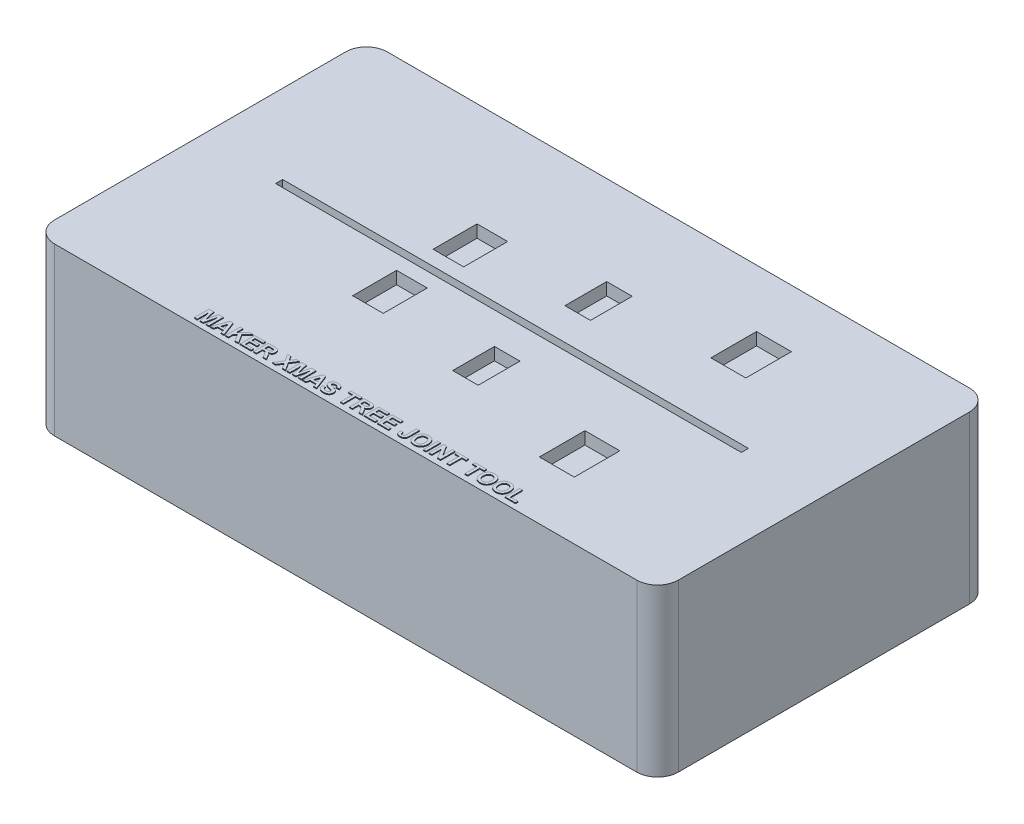
from build123d import *

# Parameters (mm, degrees)
SALIENTE_EXTRUIR1_DEPTH = 40
CROQUIS2_W              = 112
CROQUIS2_H              = 1.7
CORTAR_EXTRUIR1_DEPTH   = 37
CROQUIS4_W              = 0.673076923
CROQUIS4_H              = 3.5
SALIENTE_EXTRUIR2_DEPTH = 0.2
CROQUIS5_W              = 8.389594621
CROQUIS5_H              = 10.964379778
CROQUIS5_W_2            = 6.134235593
CROQUIS5_H_2            = 10.040470523
CROQUIS5_W_3            = 7.354274735
CROQUIS5_H_3            = 10.576819317
CROQUIS5_W_4            = 7.36371539
CROQUIS5_H_4            = 10.570248785
CROQUIS5_W_5            = 6.125268444
CROQUIS5_H_5            = 10.045943517
CROQUIS5_W_6            = 8.3993809
CROQUIS5_H_6            = 10.9568847
CORTAR_EXTRUIR2_DEPTH   = 3


with BuildPart() as part:
    # Croquis1 → Saliente-Extruir1 (new body)
    with BuildSketch(Plane(origin=(0, 0, 0), x_dir=(1, 0, 0), z_dir=(0, 1, 0))):
        with BuildLine():
            Line((-70, 40), (70, 40))
            ThreePointArc((70, 40), (73.535533906, 38.535533906), (75, 35))
            Line((75, 35), (75, -35))
            ThreePointArc((75, -35), (73.535533906, -38.535533906), (70, -40))
            Line((70, -40), (-70, -40))
            ThreePointArc((-70, -40), (-73.535533906, -38.535533906), (-75, -35))
            Line((-75, -35), (-75, 35))
            ThreePointArc((-75, 35), (-73.535533906, 38.535533906), (-70, 40))
        make_face()
    extrude(amount=SALIENTE_EXTRUIR1_DEPTH)

    # Croquis2 → Cortar-Extruir1 (cut)
    with BuildSketch(Plane(origin=(0, 40, 0), x_dir=(1, 0, 0), z_dir=(0, 1, 0))):
        Rectangle(CROQUIS2_W, CROQUIS2_H)
    extrude(amount=-CORTAR_EXTRUIR1_DEPTH, mode=Mode.SUBTRACT)

    # Croquis4 → Saliente-Extruir2 (add)
    with BuildSketch(Plane(origin=(0, 40, 0), x_dir=(1, 0, 0), z_dir=(0, 1, 0))):
        Polygon((-37.657952592, -38.693059619), (-37.657952592, -35.193059619), (-36.519330797, -35.193059619), (-35.93038849, -37.580379331), (-35.341446182, -35.193059619), (-34.202824387, -35.193059619), (-34.202824387, -38.693059619), (-34.87590131, -38.693059619), (-34.898337208, -35.937650965), (-35.555288329, -38.693059619), (-36.30548865, -38.693059619), (-36.962439772, -35.937650965), (-36.984875669, -38.693059619), align=None)
        Polygon((-30.523337208, -38.693059619), (-31.237079195, -38.693059619), (-31.532251471, -37.885367311), (-32.875600829, -37.885367311), (-33.170773105, -38.693059619), (-33.888721823, -38.693059619), (-32.565704996, -35.193059619), (-31.852664131, -35.193059619), align=None)
        Polygon((-31.746093618, -37.302033978), (-32.206029515, -36.045623722), (-32.664563169, -37.302033978), align=None, mode=Mode.SUBTRACT)
        Polygon((-30.164362849, -38.693059619), (-30.164362849, -35.193059619), (-29.491285926, -35.193059619), (-29.491285926, -36.760066831), (-28.015424547, -35.193059619), (-27.0906449, -35.193059619), (-28.419971823, -36.546224683), (-27.045773105, -38.693059619), (-27.942507881, -38.693059619), (-28.93038849, -37.067158177), (-29.491285926, -37.637871318), (-29.491285926, -38.693059619), align=None)
        Polygon((-26.664362849, -38.693059619), (-26.664362849, -35.193059619), (-24.061798746, -35.193059619), (-24.061798746, -35.776392952), (-25.991285926, -35.776392952), (-25.991285926, -36.539213465), (-24.196414131, -36.539213465), (-24.196414131, -37.122546799), (-25.991285926, -37.122546799), (-25.991285926, -38.109726286), (-24.016926951, -38.109726286), (-24.016926951, -38.693059619), align=None)
        with BuildLine():
            Line((-23.433593618, -38.693059619), (-23.433593618, -35.193059619))
            Line((-23.433593618, -35.193059619), (-21.964743458, -35.193059619))
            add(Edge.make_bspline(
                [(-21.964743458, -35.193059619), (-21.920103649, -35.193334733), (-21.834074569, -35.193864929), (-21.709659735, -35.197731218), (-21.594921331, -35.205831321), (-21.489350375, -35.215004753), (-21.393453933, -35.228351506), (-21.306852848, -35.244340785), (-21.229692919, -35.262870154), (-21.160848337, -35.285062079), (-21.098076063, -35.310461508), (-21.03960061, -35.340693974), (-20.984779023, -35.376115024), (-20.932769297, -35.415503792), (-20.88335119, -35.4589208), (-20.837879486, -35.507515075), (-20.795561946, -35.560563036), (-20.756432715, -35.617623317), (-20.721962312, -35.678443965), (-20.690465414, -35.741071711), (-20.664825751, -35.806173007), (-20.643647622, -35.873441179), (-20.626730206, -35.942730177), (-20.61498809, -36.01421616), (-20.607657614, -36.087769737), (-20.607003221, -36.137453045), (-20.606670541, -36.162711061)],
                knots=[0, 0, 0, 0, 0.000133922, 0.000258091, 0.000373334, 0.000478959, 0.000575932, 0.000663665, 0.000743078, 0.000813807, 0.000880469, 0.000946008, 0.001010967, 0.001076032, 0.001141593, 0.001208056, 0.001275396, 0.001345016, 0.00141537, 0.001484979, 0.001555154, 0.001625003, 0.001696424, 0.001768925, 0.001842178, 0.001917929, 0.001917929, 0.001917929, 0.001917929], degree=3))
            add(Edge.make_bspline(
                [(-20.606670541, -36.162711061), (-20.607287613, -36.194529093), (-20.608493542, -36.256710296), (-20.619591138, -36.347848588), (-20.636073902, -36.434924721), (-20.659569955, -36.51805933), (-20.69187655, -36.596274634), (-20.729380558, -36.670666319), (-20.774110387, -36.740982044), (-20.825762148, -36.806524739), (-20.884289599, -36.867352422), (-20.949949229, -36.922213305), (-21.02227225, -36.971321798), (-21.101696172, -37.014394712), (-21.187667961, -37.051217385), (-21.280560419, -37.082198861), (-21.379953023, -37.107414331), (-21.449090463, -37.119278963), (-21.484475028, -37.125351286)],
                knots=[0, 0, 0, 0, 9.5417e-05, 0.000186471, 0.000275024, 0.000361122, 0.000445099, 0.000528506, 0.000610779, 0.000694656, 0.000778454, 0.000863556, 0.00095087, 0.001040287, 0.001134191, 0.00123108, 0.001333789, 0.001441463, 0.001441463, 0.001441463, 0.001441463], degree=3))
            add(Edge.make_bspline(
                [(-21.484475028, -37.125351286), (-21.45025418, -37.148016075), (-21.383279318, -37.192374156), (-21.290614776, -37.265432471), (-21.207424003, -37.342112824), (-21.144436147, -37.410301763), (-21.09603647, -37.47026661), (-21.057066461, -37.522712443), (-21.01503106, -37.58306999), (-20.97034254, -37.651371953), (-20.921679798, -37.727014023), (-20.870852687, -37.811154016), (-20.816797578, -37.902971221), (-20.780454085, -37.967110186), (-20.761618458, -38.000351286)],
                knots=[0, 0, 0, 0, 0.000123098, 0.00024092, 0.000353548, 0.000462213, 0.000519043, 0.000584668, 0.000658189, 0.000739667, 0.000829522, 0.000928002, 0.00103454, 0.001149158, 0.001149158, 0.001149158, 0.001149158], degree=3))
            Line((-20.761618458, -38.000351286), (-20.337439772, -38.693059619))
            Line((-20.337439772, -38.693059619), (-21.124098426, -38.693059619))
            Line((-21.124098426, -38.693059619), (-21.6218949, -37.898688626))
            add(Edge.make_bspline(
                [(-21.6218949, -37.898688626), (-21.644756682, -37.866874641), (-21.688404523, -37.806135203), (-21.751412879, -37.71982249), (-21.809059933, -37.642988674), (-21.859811503, -37.57452086), (-21.906235599, -37.516360271), (-21.9469226, -37.467493372), (-21.981043765, -37.426871549), (-22.019651947, -37.386593257), (-22.064568468, -37.345198393), (-22.120171534, -37.305063716), (-22.177270723, -37.273068775), (-22.238447944, -37.248655883), (-22.309197551, -37.231633593), (-22.394249783, -37.22078823), (-22.496278881, -37.212786643), (-22.570025478, -37.212464192), (-22.609775509, -37.212290388)],
                knots=[0, 0, 0, 0, 0.000117529, 0.000224388, 0.000320582, 0.000405698, 0.000480047, 0.000543784, 0.000596485, 0.000639132, 0.000711102, 0.000779403, 0.00084437, 0.000906993, 0.000976373, 0.001062042, 0.001163996, 0.001283206, 0.001283206, 0.001283206, 0.001283206], degree=3))
            Line((-22.609775509, -37.212290388), (-22.760516695, -37.212290388))
            Line((-22.760516695, -37.212290388), (-22.760516695, -38.693059619))
            Line((-22.760516695, -38.693059619), (-23.433593618, -38.693059619))
        make_face()
        with BuildLine():
            Line((-22.760516695, -36.628957055), (-22.218549547, -36.628957055))
            add(Edge.make_bspline(
                [(-22.218549547, -36.628957055), (-22.176713927, -36.628867399), (-22.097010001, -36.628696588), (-21.983669433, -36.626222469), (-21.882418141, -36.624122541), (-21.793862038, -36.618846382), (-21.717604917, -36.613617212), (-21.653952684, -36.606821187), (-21.602369051, -36.598788505), (-21.550845672, -36.586299794), (-21.498068226, -36.564540681), (-21.441817453, -36.533549299), (-21.39374131, -36.493345071), (-21.352096266, -36.446864918), (-21.320326932, -36.392223271), (-21.295444029, -36.331854477), (-21.28282787, -36.264417088), (-21.280795781, -36.217674195), (-21.279747464, -36.19356042)],
                knots=[0, 0, 0, 0, 0.000125503, 0.000239104, 0.000340104, 0.000429282, 0.000505211, 0.000569397, 0.000621266, 0.000661737, 0.000728136, 0.000791881, 0.000853643, 0.000915246, 0.000978133, 0.001042319, 0.001110244, 0.001182626, 0.001182626, 0.001182626, 0.001182626], degree=3))
            add(Edge.make_bspline(
                [(-21.279747464, -36.19356042), (-21.280939727, -36.166584178), (-21.283240007, -36.114537867), (-21.301380338, -36.040475471), (-21.333043546, -35.975051541), (-21.376529149, -35.91815806), (-21.431118474, -35.870116384), (-21.496140395, -35.831981751), (-21.571111848, -35.803580658), (-21.625186101, -35.793092189), (-21.653445381, -35.787610901)],
                knots=[0, 0, 0, 0, 8.0876e-05, 0.000156036, 0.000226905, 0.00029744, 0.000369465, 0.000443655, 0.000522434, 0.000608671, 0.000608671, 0.000608671, 0.000608671], degree=3))
            add(Edge.make_bspline(
                [(-21.653445381, -35.787610901), (-21.662786514, -35.786584511), (-21.684926962, -35.784151752), (-21.724024369, -35.782589297), (-21.774015419, -35.780187635), (-21.835505204, -35.779206128), (-21.907944378, -35.777485635), (-21.991620992, -35.777169709), (-22.086269198, -35.776160347), (-22.153111108, -35.776312579), (-22.18840131, -35.776392952)],
                knots=[0, 0, 0, 0, 2.8185e-05, 6.6804e-05, 0.000117328, 0.000178342, 0.000251272, 0.000334709, 0.000429363, 0.000535232, 0.000535232, 0.000535232, 0.000535232], degree=3))
            Line((-22.18840131, -35.776392952), (-22.760516695, -35.776392952))
            Line((-22.760516695, -35.776392952), (-22.760516695, -36.628957055))
        make_face(mode=Mode.SUBTRACT)
        Polygon((-18.923978233, -38.693059619), (-17.724358842, -36.839293593), (-18.789362849, -35.193059619), (-18.002704195, -35.193059619), (-17.331029515, -36.231420997), (-16.659354836, -35.193059619), (-15.872696182, -35.193059619), (-16.937700188, -36.839293593), (-15.738080797, -38.693059619), (-16.524739451, -38.693059619), (-17.331029515, -37.44716619), (-18.137319579, -38.693059619), align=None)
        Polygon((-15.401542336, -38.693059619), (-15.401542336, -35.193059619), (-14.262920541, -35.193059619), (-13.673978233, -37.580379331), (-13.085035926, -35.193059619), (-11.946414131, -35.193059619), (-11.946414131, -38.693059619), (-12.619491054, -38.693059619), (-12.641926951, -35.937650965), (-13.298878073, -38.693059619), (-14.049078394, -38.693059619), (-14.706029515, -35.937650965), (-14.728465413, -38.693059619), align=None)
        Polygon((-8.266926951, -38.693059619), (-8.980668938, -38.693059619), (-9.275841214, -37.885367311), (-10.619190573, -37.885367311), (-10.914362849, -38.693059619), (-11.632311567, -38.693059619), (-10.30929474, -35.193059619), (-9.596253874, -35.193059619), align=None)
        Polygon((-9.489683362, -37.302033978), (-9.949619259, -36.045623722), (-10.408152913, -37.302033978), align=None, mode=Mode.SUBTRACT)
        with BuildLine():
            Line((-8.087439772, -37.526392952), (-7.414362849, -37.481521158))
            add(Edge.make_bspline(
                [(-7.414362849, -37.481521158), (-7.409000635, -37.509680326), (-7.398584877, -37.564377719), (-7.375443018, -37.642328972), (-7.349970236, -37.715001648), (-7.319528865, -37.781616453), (-7.28620334, -37.843404726), (-7.247255956, -37.898606268), (-7.205403781, -37.948983523), (-7.158575052, -37.992727155), (-7.107555759, -38.031038432), (-7.052091322, -38.063711565), (-6.992782745, -38.091990752), (-6.929485012, -38.115277766), (-6.861545742, -38.132661636), (-6.789556787, -38.145029228), (-6.713414901, -38.152949093), (-6.661377985, -38.154039421), (-6.634715413, -38.154598081)],
                knots=[0, 0, 0, 0, 8.5941e-05, 0.000166935, 0.000243669, 0.000316781, 0.000386446, 0.000453936, 0.00051911, 0.0005826, 0.000645701, 0.00071015, 0.000775381, 0.00084259, 0.000912143, 0.000985453, 0.001061566, 0.001141543, 0.001141543, 0.001141543, 0.001141543], degree=3))
            add(Edge.make_bspline(
                [(-6.634715413, -38.154598081), (-6.606651369, -38.154291904), (-6.552065358, -38.153696374), (-6.472964193, -38.146308302), (-6.39900101, -38.135724093), (-6.330828931, -38.118969539), (-6.267174908, -38.100232222), (-6.20961984, -38.074597576), (-6.157232351, -38.045031717), (-6.110147403, -38.011482128), (-6.069056325, -37.974273226), (-6.033107799, -37.93542834), (-6.001799007, -37.895786697), (-5.977156772, -37.853589174), (-5.957214142, -37.810542414), (-5.94403346, -37.765362258), (-5.935129129, -37.719086139), (-5.934108062, -37.687459566), (-5.933593618, -37.671525164)],
                knots=[0, 0, 0, 0, 8.4161e-05, 0.000163697, 0.000238165, 0.000308059, 0.000374144, 0.000436932, 0.000496589, 0.000554376, 0.000609981, 0.00066257, 0.000713056, 0.000761153, 0.00080885, 0.000854985, 0.000902018, 0.000949777, 0.000949777, 0.000949777, 0.000949777], degree=3))
            add(Edge.make_bspline(
                [(-5.933593618, -37.671525164), (-5.93422454, -37.651560651), (-5.935458846, -37.612503003), (-5.950318653, -37.556665816), (-5.972603327, -37.504934276), (-6.006156345, -37.458072458), (-6.051259861, -37.415247586), (-6.108793889, -37.375185966), (-6.180364404, -37.339146177), (-6.233460416, -37.319043115), (-6.261718618, -37.308344074)],
                knots=[0, 0, 0, 0, 5.9744e-05, 0.00011688, 0.000172122, 0.000227952, 0.000288444, 0.000357887, 0.000437535, 0.00052815, 0.00052815, 0.00052815, 0.00052815], degree=3))
            add(Edge.make_bspline(
                [(-6.261718618, -37.308344074), (-6.273843464, -37.304280982), (-6.300976901, -37.295188442), (-6.347263664, -37.282186968), (-6.4030173, -37.26595158), (-6.469043483, -37.24749747), (-6.545320013, -37.228623774), (-6.630994981, -37.205373522), (-6.727112859, -37.18223762), (-6.794357043, -37.165158703), (-6.829627272, -37.156200645)],
                knots=[0, 0, 0, 0, 3.8357e-05, 8.5837e-05, 0.000144199, 0.000212579, 0.000291482, 0.000379913, 0.00047888, 0.000588051, 0.000588051, 0.000588051, 0.000588051], degree=3))
            add(Edge.make_bspline(
                [(-6.829627272, -37.156200645), (-6.875559578, -37.14473242), (-6.964178452, -37.122606355), (-7.090569258, -37.083245654), (-7.206977503, -37.044138618), (-7.312282362, -37.001705386), (-7.407645393, -36.958821771), (-7.491524069, -36.912477061), (-7.565668754, -36.865078099), (-7.608874583, -36.829650957), (-7.62960724, -36.812650965)],
                knots=[0, 0, 0, 0, 0.000141996, 0.000273958, 0.000397014, 0.000510284, 0.00061444, 0.00071046, 0.00079758, 0.000877953, 0.000877953, 0.000877953, 0.000877953], degree=3))
            add(Edge.make_bspline(
                [(-7.62960724, -36.812650965), (-7.655318429, -36.78857769), (-7.705727592, -36.741379807), (-7.772083432, -36.663824627), (-7.827840406, -36.581899988), (-7.8737345, -36.496210603), (-7.909072084, -36.406263162), (-7.934118909, -36.312659736), (-7.950330125, -36.215156029), (-7.951984367, -36.148753695), (-7.952824387, -36.115034779)],
                knots=[0, 0, 0, 0, 0.000105609, 0.000207056, 0.000305456, 0.000402376, 0.000498071, 0.000594675, 0.000692652, 0.000793733, 0.000793733, 0.000793733, 0.000793733], degree=3))
            add(Edge.make_bspline(
                [(-7.952824387, -36.115034779), (-7.951188442, -36.071402905), (-7.947943215, -35.984850289), (-7.918182368, -35.857629759), (-7.871823101, -35.734871747), (-7.818057343, -35.637397339), (-7.766400051, -35.56365758), (-7.72350243, -35.510742604), (-7.676375249, -35.461219274), (-7.624372966, -35.41629562), (-7.569426553, -35.373340206), (-7.509407176, -35.335195284), (-7.446016566, -35.299264878), (-7.354283131, -35.256671053), (-7.229734298, -35.212284104), (-7.067689575, -35.174868723), (-6.891254959, -35.152377246), (-6.768932297, -35.149618017), (-6.705528714, -35.148187824)],
                knots=[0, 0, 0, 0, 0.000130727, 0.000259323, 0.000389799, 0.000523479, 0.000591945, 0.000659726, 0.000727662, 0.000796718, 0.000865714, 0.000936697, 0.001009836, 0.001084171, 0.001239855, 0.001405498, 0.001582208, 0.001772369, 0.001772369, 0.001772369, 0.001772369], degree=3))
            add(Edge.make_bspline(
                [(-6.705528714, -35.148187824), (-6.653613807, -35.148882057), (-6.552640422, -35.150232324), (-6.406267772, -35.163886442), (-6.269547775, -35.185137462), (-6.142960198, -35.215643203), (-6.02644606, -35.255949293), (-5.919553717, -35.303961467), (-5.822374003, -35.360963965), (-5.736089984, -35.427283905), (-5.659219194, -35.500397385), (-5.592161723, -35.580258524), (-5.534661198, -35.665858727), (-5.486346517, -35.757135436), (-5.448405125, -35.854557947), (-5.420538671, -35.958004696), (-5.402107556, -36.067232196), (-5.397487741, -36.14207597), (-5.395132079, -36.180239106)],
                knots=[0, 0, 0, 0, 0.000155706, 0.000302845, 0.000440588, 0.000570506, 0.000692899, 0.000809936, 0.000921522, 0.00103006, 0.001135688, 0.001239193, 0.001342256, 0.001444497, 0.001548396, 0.001655208, 0.0017654, 0.001880046, 0.001880046, 0.001880046, 0.001880046], degree=3))
            Line((-5.395132079, -36.180239106), (-6.068209003, -36.225110901))
            add(Edge.make_bspline(
                [(-6.068209003, -36.225110901), (-6.072091813, -36.204005014), (-6.079659008, -36.162871835), (-6.096112161, -36.103960766), (-6.114670519, -36.049474746), (-6.136392116, -35.999414126), (-6.16262918, -35.954675537), (-6.191182646, -35.913851482), (-6.222840173, -35.877485916), (-6.258649955, -35.846574648), (-6.297381415, -35.81844666), (-6.341521628, -35.795901427), (-6.389221072, -35.774984413), (-6.442294421, -35.759259948), (-6.499722474, -35.746786737), (-6.561538683, -35.73753991), (-6.627871184, -35.733025088), (-6.673505499, -35.732033944), (-6.697115253, -35.731521158)],
                knots=[0, 0, 0, 0, 6.4351e-05, 0.000125413, 0.000183284, 0.00023696, 0.000288791, 0.00033859, 0.000386277, 0.000432974, 0.000480246, 0.00052949, 0.00058132, 0.000636322, 0.000695183, 0.000757551, 0.000823639, 0.000894483, 0.000894483, 0.000894483, 0.000894483], degree=3))
            add(Edge.make_bspline(
                [(-6.697115253, -35.731521158), (-6.721662948, -35.731973864), (-6.769421587, -35.732854624), (-6.839018652, -35.738259719), (-6.904305922, -35.748237003), (-6.965604039, -35.761224953), (-7.022831124, -35.77889416), (-7.075866411, -35.800438864), (-7.12495254, -35.825803613), (-7.154883121, -35.845759721), (-7.169671342, -35.855619715)],
                knots=[0, 0, 0, 0, 7.3648e-05, 0.000143285, 0.000209224, 0.000271659, 0.000331094, 0.000388641, 0.000443207, 0.000496497, 0.000496497, 0.000496497, 0.000496497], degree=3))
            add(Edge.make_bspline(
                [(-7.169671342, -35.855619715), (-7.18659522, -35.869088748), (-7.219371518, -35.895174082), (-7.254645751, -35.946970688), (-7.275880921, -36.005473401), (-7.278436814, -36.046844644), (-7.279747464, -36.068059619)],
                knots=[0, 0, 0, 0, 6.4572e-05, 0.000125055, 0.000185376, 0.000248866, 0.000248866, 0.000248866, 0.000248866], degree=3))
            add(Edge.make_bspline(
                [(-7.279747464, -36.068059619), (-7.278675591, -36.087886422), (-7.276564173, -36.126942068), (-7.255267797, -36.182421458), (-7.222516872, -36.233827103), (-7.191916504, -36.261751324), (-7.175981438, -36.276292792)],
                knots=[0, 0, 0, 0, 5.9231e-05, 0.000116676, 0.00017599, 0.00024044, 0.00024044, 0.00024044, 0.00024044], degree=3))
            add(Edge.make_bspline(
                [(-7.175981438, -36.276292792), (-7.163334911, -36.285730935), (-7.135075185, -36.306821255), (-7.083308969, -36.333629048), (-7.020825788, -36.362663506), (-6.946201176, -36.391047895), (-6.859931086, -36.419379595), (-6.762010273, -36.448961165), (-6.652378511, -36.478939896), (-6.53383026, -36.507972828), (-6.413470395, -36.536510532), (-6.298614294, -36.567710298), (-6.191814636, -36.598127656), (-6.093566622, -36.630009984), (-6.003363801, -36.661047331), (-5.921644346, -36.692924922), (-5.847847141, -36.723970129), (-5.761791419, -36.766659487), (-5.664255913, -36.824483948), (-5.562027699, -36.908541445), (-5.47161989, -37.003027562), (-5.408626131, -37.092121453), (-5.365352715, -37.16874457), (-5.3374892, -37.229822116), (-5.313385075, -37.294182449), (-5.293764383, -37.361896691), (-5.279544102, -37.433060126), (-5.267775992, -37.507129063), (-5.261763446, -37.584718661), (-5.260936751, -37.637629246), (-5.260516695, -37.664513946)],
                knots=[0, 0, 0, 0, 4.7272e-05, 0.000105634, 0.000174337, 0.000254022, 0.000344924, 0.000446732, 0.000560862, 0.000685847, 0.000812874, 0.000931924, 0.00104287, 0.001145973, 0.001241763, 0.001328998, 0.001409092, 0.001481836, 0.001617109, 0.001748182, 0.001877624, 0.002008356, 0.002074276, 0.002141412, 0.002209522, 0.002280308, 0.002352635, 0.002427103, 0.002505183, 0.002585839, 0.002585839, 0.002585839, 0.002585839], degree=3))
            add(Edge.make_bspline(
                [(-5.260516695, -37.664513946), (-5.261094286, -37.68930765), (-5.262241326, -37.738545546), (-5.270257155, -37.811627012), (-5.282653432, -37.883410687), (-5.301004182, -37.95398656), (-5.325348325, -38.023215792), (-5.352757895, -38.092097555), (-5.387032018, -38.15912968), (-5.426040646, -38.224367687), (-5.469068934, -38.28776262), (-5.517827977, -38.346243002), (-5.569453859, -38.401759878), (-5.627245336, -38.451204615), (-5.687633655, -38.498580779), (-5.753380915, -38.540537906), (-5.822946754, -38.578505392), (-5.896771024, -38.61219977), (-5.975115474, -38.641561374), (-6.057878349, -38.667695244), (-6.145805294, -38.689083809), (-6.238163123, -38.707416504), (-6.335289826, -38.721358044), (-6.437063971, -38.731092481), (-6.543508697, -38.736582117), (-6.616012715, -38.73747606), (-6.652944579, -38.737931414)],
                knots=[0, 0, 0, 0, 7.4372e-05, 0.000147695, 0.000220315, 0.000292758, 0.000366148, 0.000440361, 0.000514987, 0.000591701, 0.000668326, 0.000744542, 0.000819925, 0.000895445, 0.000972434, 0.001050031, 0.001129096, 0.001210042, 0.001293251, 0.001379955, 0.00147025, 0.001564577, 0.001662342, 0.001764478, 0.001871196, 0.001981993, 0.001981993, 0.001981993, 0.001981993], degree=3))
            add(Edge.make_bspline(
                [(-6.652944579, -38.737931414), (-6.706268494, -38.73706081), (-6.81009142, -38.735365725), (-6.960927486, -38.720193373), (-7.10240173, -38.696970994), (-7.234283843, -38.663267489), (-7.356735017, -38.619999796), (-7.469699403, -38.566703553), (-7.572630607, -38.503060341), (-7.666803485, -38.430613617), (-7.750963333, -38.348043219), (-7.826640037, -38.257059973), (-7.892812698, -38.156844591), (-7.949437821, -38.047553824), (-7.997946987, -37.929778495), (-8.037952963, -37.803464524), (-8.068075361, -37.668009462), (-8.080873332, -37.574414874), (-8.087439772, -37.526392952)],
                knots=[0, 0, 0, 0, 0.000159931, 0.00031139, 0.000454317, 0.000589677, 0.000719186, 0.000843377, 0.000963627, 0.00108157, 0.001199076, 0.001316585, 0.001435982, 0.0015586, 0.001685288, 0.001817666, 0.001955616, 0.00210098, 0.00210098, 0.00210098, 0.00210098], degree=3))
        make_face()
        Polygon((-2.523337208, -38.693059619), (-2.523337208, -35.776392952), (-3.55538849, -35.776392952), (-3.55538849, -35.193059619), (-0.818209003, -35.193059619), (-0.818209003, -35.776392952), (-1.850260285, -35.776392952), (-1.850260285, -38.693059619), align=None)
        with BuildLine():
            Line((-0.369491054, -38.693059619), (-0.369491054, -35.193059619))
            Line((-0.369491054, -35.193059619), (1.099359106, -35.193059619))
            add(Edge.make_bspline(
                [(1.099359106, -35.193059619), (1.143998915, -35.193334733), (1.230027995, -35.193864929), (1.354442829, -35.197731218), (1.469181233, -35.205831321), (1.574752189, -35.215004753), (1.670648631, -35.228351506), (1.757249716, -35.244340785), (1.834409645, -35.262870154), (1.903254227, -35.285062079), (1.966026501, -35.310461508), (2.024501954, -35.340693974), (2.079323541, -35.376115024), (2.131333267, -35.415503792), (2.180751374, -35.4589208), (2.226223078, -35.507515075), (2.268540618, -35.560563036), (2.307669849, -35.617623317), (2.342140252, -35.678443965), (2.37363715, -35.741071711), (2.399276813, -35.806173007), (2.420454942, -35.873441179), (2.437372358, -35.942730177), (2.449114474, -36.01421616), (2.45644495, -36.087769737), (2.457099343, -36.137453045), (2.457432023, -36.162711061)],
                knots=[0, 0, 0, 0, 0.000133922, 0.000258091, 0.000373334, 0.000478959, 0.000575932, 0.000663665, 0.000743078, 0.000813807, 0.000880469, 0.000946008, 0.001010967, 0.001076032, 0.001141593, 0.001208056, 0.001275396, 0.001345016, 0.00141537, 0.001484979, 0.001555154, 0.001625003, 0.001696424, 0.001768925, 0.001842178, 0.001917929, 0.001917929, 0.001917929, 0.001917929], degree=3))
            add(Edge.make_bspline(
                [(2.457432023, -36.162711061), (2.456814951, -36.194529093), (2.455609022, -36.256710296), (2.444511426, -36.347848588), (2.428028662, -36.434924721), (2.404532609, -36.51805933), (2.372226014, -36.596274634), (2.334722006, -36.670666319), (2.289992177, -36.740982044), (2.238340416, -36.806524739), (2.179812965, -36.867352422), (2.114153335, -36.922213305), (2.041830314, -36.971321798), (1.962406393, -37.014394712), (1.876434604, -37.051217385), (1.783542145, -37.082198861), (1.684149541, -37.107414331), (1.615012101, -37.119278963), (1.579627536, -37.125351286)],
                knots=[0, 0, 0, 0, 9.5417e-05, 0.000186471, 0.000275024, 0.000361122, 0.000445099, 0.000528506, 0.000610779, 0.000694656, 0.000778454, 0.000863556, 0.00095087, 0.001040287, 0.001134191, 0.00123108, 0.001333789, 0.001441463, 0.001441463, 0.001441463, 0.001441463], degree=3))
            add(Edge.make_bspline(
                [(1.579627536, -37.125351286), (1.613848384, -37.148016075), (1.680823246, -37.192374156), (1.773487788, -37.265432471), (1.856678561, -37.342112824), (1.919666417, -37.410301763), (1.968066094, -37.47026661), (2.007036103, -37.522712443), (2.049071505, -37.58306999), (2.093760024, -37.651371953), (2.142422766, -37.727014023), (2.193249877, -37.811154016), (2.247304986, -37.902971221), (2.283648479, -37.967110186), (2.302484106, -38.000351286)],
                knots=[0, 0, 0, 0, 0.000123098, 0.00024092, 0.000353548, 0.000462213, 0.000519043, 0.000584668, 0.000658189, 0.000739667, 0.000829522, 0.000928002, 0.00103454, 0.001149158, 0.001149158, 0.001149158, 0.001149158], degree=3))
            Line((2.302484106, -38.000351286), (2.726662792, -38.693059619))
            Line((2.726662792, -38.693059619), (1.940004138, -38.693059619))
            Line((1.940004138, -38.693059619), (1.442207664, -37.898688626))
            add(Edge.make_bspline(
                [(1.442207664, -37.898688626), (1.419345882, -37.866874641), (1.375698041, -37.806135203), (1.312689685, -37.71982249), (1.255042632, -37.642988674), (1.204291061, -37.57452086), (1.157866965, -37.516360271), (1.117179964, -37.467493372), (1.083058799, -37.426871549), (1.044450617, -37.386593257), (0.999534096, -37.345198393), (0.94393103, -37.305063716), (0.886831841, -37.273068775), (0.82565462, -37.248655883), (0.754905013, -37.231633593), (0.669852781, -37.22078823), (0.567823683, -37.212786643), (0.494077086, -37.212464192), (0.454327055, -37.212290388)],
                knots=[0, 0, 0, 0, 0.000117529, 0.000224388, 0.000320582, 0.000405698, 0.000480047, 0.000543784, 0.000596485, 0.000639132, 0.000711102, 0.000779403, 0.00084437, 0.000906993, 0.000976373, 0.001062042, 0.001163996, 0.001283206, 0.001283206, 0.001283206, 0.001283206], degree=3))
            Line((0.454327055, -37.212290388), (0.303585869, -37.212290388))
            Line((0.303585869, -37.212290388), (0.303585869, -38.693059619))
            Line((0.303585869, -38.693059619), (-0.369491054, -38.693059619))
        make_face()
        with BuildLine():
            Line((0.303585869, -36.628957055), (0.845553017, -36.628957055))
            add(Edge.make_bspline(
                [(0.845553017, -36.628957055), (0.887388637, -36.628867399), (0.967092563, -36.628696588), (1.080433131, -36.626222469), (1.181684423, -36.624122541), (1.270240526, -36.618846382), (1.346497647, -36.613617212), (1.41014988, -36.606821187), (1.461733513, -36.598788505), (1.513256892, -36.586299794), (1.566034338, -36.564540681), (1.622285111, -36.533549299), (1.670361254, -36.493345071), (1.712006298, -36.446864918), (1.743775632, -36.392223271), (1.768658535, -36.331854477), (1.781274694, -36.264417088), (1.783306783, -36.217674195), (1.7843551, -36.19356042)],
                knots=[0, 0, 0, 0, 0.000125503, 0.000239104, 0.000340104, 0.000429282, 0.000505211, 0.000569397, 0.000621266, 0.000661737, 0.000728136, 0.000791881, 0.000853643, 0.000915246, 0.000978133, 0.001042319, 0.001110244, 0.001182626, 0.001182626, 0.001182626, 0.001182626], degree=3))
            add(Edge.make_bspline(
                [(1.7843551, -36.19356042), (1.783162837, -36.166584178), (1.780862557, -36.114537867), (1.762722227, -36.040475471), (1.731059018, -35.975051541), (1.687573415, -35.91815806), (1.63298409, -35.870116384), (1.567962169, -35.831981751), (1.492990716, -35.803580658), (1.438916463, -35.793092189), (1.410657183, -35.787610901)],
                knots=[0, 0, 0, 0, 8.0876e-05, 0.000156036, 0.000226905, 0.00029744, 0.000369465, 0.000443655, 0.000522434, 0.000608671, 0.000608671, 0.000608671, 0.000608671], degree=3))
            add(Edge.make_bspline(
                [(1.410657183, -35.787610901), (1.40131605, -35.786584511), (1.379175602, -35.784151752), (1.340078195, -35.782589297), (1.290087145, -35.780187635), (1.22859736, -35.779206128), (1.156158186, -35.777485635), (1.072481572, -35.777169709), (0.977833366, -35.776160347), (0.910991456, -35.776312579), (0.875701254, -35.776392952)],
                knots=[0, 0, 0, 0, 2.8185e-05, 6.6804e-05, 0.000117328, 0.000178342, 0.000251272, 0.000334709, 0.000429363, 0.000535232, 0.000535232, 0.000535232, 0.000535232], degree=3))
            Line((0.875701254, -35.776392952), (0.303585869, -35.776392952))
            Line((0.303585869, -35.776392952), (0.303585869, -36.628957055))
        make_face(mode=Mode.SUBTRACT)
        Polygon((3.130508946, -38.693059619), (3.130508946, -35.193059619), (5.733073049, -35.193059619), (5.733073049, -35.776392952), (3.803585869, -35.776392952), (3.803585869, -36.539213465), (5.598457664, -36.539213465), (5.598457664, -37.122546799), (3.803585869, -37.122546799), (3.803585869, -38.109726286), (5.777944844, -38.109726286), (5.777944844, -38.693059619), align=None)
        Polygon((6.361278177, -38.693059619), (6.361278177, -35.193059619), (8.963842279, -35.193059619), (8.963842279, -35.776392952), (7.0343551, -35.776392952), (7.0343551, -36.539213465), (8.829226895, -36.539213465), (8.829226895, -37.122546799), (7.0343551, -37.122546799), (7.0343551, -38.109726286), (9.008714074, -38.109726286), (9.008714074, -38.693059619), align=None)
        with BuildLine():
            Line((12.239483305, -35.193059619), (12.912560228, -35.193059619))
            Line((12.912560228, -35.193059619), (12.912560228, -37.399489908))
            add(Edge.make_bspline(
                [(12.912560228, -37.399489908), (12.912259447, -37.434549291), (12.911675778, -37.50258228), (12.908089413, -37.60146727), (12.902753505, -37.694084738), (12.894545043, -37.78042139), (12.882978854, -37.860290587), (12.870721107, -37.934329424), (12.855838722, -38.002163696), (12.842502505, -38.044601534), (12.836137953, -38.064854491)],
                knots=[0, 0, 0, 0, 0.000105178, 0.000204098, 0.000296816, 0.000383463, 0.000464175, 0.000538866, 0.000608602, 0.000672266, 0.000672266, 0.000672266, 0.000672266], degree=3))
            add(Edge.make_bspline(
                [(12.836137953, -38.064854491), (12.82724342, -38.089811651), (12.809640625, -38.139203312), (12.77542642, -38.209658406), (12.73608185, -38.276360151), (12.691717647, -38.339597606), (12.642752851, -38.399624313), (12.587526666, -38.454858109), (12.527981798, -38.507225591), (12.46244332, -38.554556799), (12.392560666, -38.598687857), (12.316343143, -38.635456084), (12.23529036, -38.667261088), (12.148722065, -38.693094377), (12.056613154, -38.713307363), (11.9591996, -38.728019769), (11.856351631, -38.736379663), (11.786106367, -38.737405562), (11.750100292, -38.737931414)],
                knots=[0, 0, 0, 0, 7.9434e-05, 0.000157205, 0.000234523, 0.000311547, 0.00038875, 0.000466587, 0.000545603, 0.000626378, 0.000708873, 0.00079322, 0.000879802, 0.000969858, 0.001063928, 0.00116249, 0.001265199, 0.001373208, 0.001373208, 0.001373208, 0.001373208], degree=3))
            add(Edge.make_bspline(
                [(11.750100292, -38.737931414), (11.70799981, -38.736913867), (11.626152675, -38.734935663), (11.507131264, -38.721802198), (11.395515468, -38.698831215), (11.291641141, -38.665651711), (11.194446863, -38.624406403), (11.105108214, -38.572958542), (11.023150391, -38.512340313), (10.949106346, -38.442365925), (10.882939477, -38.363742988), (10.825825639, -38.275781688), (10.777351203, -38.179401902), (10.738289079, -38.074167609), (10.707449446, -37.960582627), (10.685205253, -37.8384078), (10.671931881, -37.707573559), (10.669976499, -37.617570127), (10.668970485, -37.571264747)],
                knots=[0, 0, 0, 0, 0.000126297, 0.000245533, 0.000358701, 0.000467574, 0.000572156, 0.00067486, 0.000776104, 0.000877284, 0.000979802, 0.001083646, 0.001191194, 0.001302796, 0.001419816, 0.001543857, 0.001674945, 0.001813853, 0.001813853, 0.001813853, 0.001813853], degree=3))
            Line((10.668970485, -37.571264747), (11.342047408, -37.526392952))
            add(Edge.make_bspline(
                [(11.342047408, -37.526392952), (11.34325627, -37.551179154), (11.345574331, -37.598708084), (11.352010792, -37.667223169), (11.360149825, -37.73019656), (11.370799581, -37.787439246), (11.382268194, -37.839434913), (11.397166101, -37.885160302), (11.41282821, -37.926223254), (11.426584813, -37.950248354), (11.433193241, -37.961789587)],
                knots=[0, 0, 0, 0, 7.4438e-05, 0.000142739, 0.000206398, 0.000264844, 0.000317396, 0.000365956, 0.00040905, 0.000448891, 0.000448891, 0.000448891, 0.000448891], degree=3))
            add(Edge.make_bspline(
                [(11.433193241, -37.961789587), (11.443310073, -37.977054321), (11.463221257, -38.007097217), (11.499544537, -38.046246272), (11.538541194, -38.080472564), (11.582344583, -38.107381294), (11.629735435, -38.128544201), (11.681069506, -38.143921958), (11.736205263, -38.153246306), (11.774134879, -38.154140103), (11.793569844, -38.154598081)],
                knots=[0, 0, 0, 0, 5.4854e-05, 0.000107959, 0.000159671, 0.000210059, 0.000261528, 0.000314984, 0.000370426, 0.000428686, 0.000428686, 0.000428686, 0.000428686], degree=3))
            add(Edge.make_bspline(
                [(11.793569844, -38.154598081), (11.813220065, -38.154231905), (11.85099406, -38.153527999), (11.90543077, -38.14712711), (11.955482628, -38.136755205), (12.001176896, -38.122175928), (12.042668358, -38.103249882), (12.079037317, -38.079037282), (12.111850952, -38.051792626), (12.140196753, -38.019019196), (12.16434793, -37.979529839), (12.184513066, -37.931466085), (12.201860584, -37.874630233), (12.215267629, -37.808590196), (12.226679669, -37.733978203), (12.233838204, -37.650134551), (12.238983812, -37.557307044), (12.239312153, -37.492280145), (12.239483305, -37.458384138)],
                knots=[0, 0, 0, 0, 5.8932e-05, 0.000113286, 0.000164164, 0.000212056, 0.000256912, 0.000300472, 0.000342755, 0.000384505, 0.00042984, 0.000481027, 0.000540461, 0.000607842, 0.000683003, 0.000766792, 0.00086017, 0.000961842, 0.000961842, 0.000961842, 0.000961842], degree=3))
            Line((12.239483305, -37.458384138), (12.239483305, -35.193059619))
        make_face()
        with BuildLine():
            add(Edge.make_bspline(
                [(13.495893562, -36.964093273), (13.496141242, -36.920841717), (13.496627655, -36.835901245), (13.505056062, -36.711290384), (13.51616536, -36.591846221), (13.534256833, -36.478038574), (13.55553901, -36.369334783), (13.582157365, -36.265767117), (13.614223057, -36.167698784), (13.639731568, -36.105083214), (13.652243722, -36.074369715)],
                knots=[0, 0, 0, 0, 0.000129725, 0.000254762, 0.000374548, 0.000489474, 0.0006003, 0.000706753, 0.000810072, 0.000909543, 0.000909543, 0.000909543, 0.000909543], degree=3))
            add(Edge.make_bspline(
                [(13.652243722, -36.074369715), (13.672696344, -36.03070692), (13.713361033, -35.943894874), (13.788881752, -35.821222475), (13.874480034, -35.705532463), (13.969451172, -35.597431333), (14.071370522, -35.498546487), (14.180718894, -35.413915297), (14.293611467, -35.340679588), (14.373903716, -35.303846379), (14.413661991, -35.285607696)],
                knots=[0, 0, 0, 0, 0.00014455, 0.0002874, 0.000431274, 0.000575849, 0.000718662, 0.000856528, 0.000990155, 0.001121226, 0.001121226, 0.001121226, 0.001121226], degree=3))
            add(Edge.make_bspline(
                [(14.413661991, -35.285607696), (14.440649759, -35.274537916), (14.49519892, -35.252163067), (14.579974737, -35.224238084), (14.667967188, -35.201550297), (14.75853983, -35.181270059), (14.852572046, -35.167286167), (14.949304019, -35.155561155), (15.049265128, -35.149415872), (15.11688009, -35.148601626), (15.151242119, -35.148187824)],
                knots=[0, 0, 0, 0, 8.7491e-05, 0.000176843, 0.000267485, 0.000360036, 0.000455133, 0.000552536, 0.000652295, 0.000755382, 0.000755382, 0.000755382, 0.000755382], degree=3))
            add(Edge.make_bspline(
                [(15.151242119, -35.148187824), (15.212769994, -35.149730126), (15.333180892, -35.152748432), (15.5090674, -35.174549296), (15.67550944, -35.211362062), (15.831943603, -35.264570153), (15.979718615, -35.331081423), (16.117686354, -35.413581078), (16.246051013, -35.511176222), (16.364564664, -35.62252851), (16.471294695, -35.747443884), (16.564247685, -35.884755449), (16.642222677, -36.033819748), (16.706439585, -36.194225508), (16.75578544, -36.366496664), (16.791437774, -36.550147135), (16.812618147, -36.745312196), (16.815120988, -36.879204073), (16.816406382, -36.947967472)],
                knots=[0, 0, 0, 0, 0.000184556, 0.000361179, 0.000530765, 0.000695057, 0.000856019, 0.00101606, 0.001176199, 0.001338886, 0.001502997, 0.001668094, 0.001835253, 0.002006719, 0.002185562, 0.002372015, 0.002567362, 0.002773611, 0.002773611, 0.002773611, 0.002773611], degree=3))
            add(Edge.make_bspline(
                [(16.816406382, -36.947967472), (16.815150676, -37.016270422), (16.812706052, -37.149243504), (16.791130335, -37.342877096), (16.756956094, -37.52518875), (16.706416266, -37.695762001), (16.644115963, -37.855898435), (16.565338589, -38.0036907), (16.474332315, -38.141099163), (16.367753874, -38.264668476), (16.251234876, -38.376659816), (16.12303304, -38.473114317), (15.986069639, -38.555725756), (15.839100324, -38.622429232), (15.683083013, -38.674541522), (15.517508554, -38.711637167), (15.34229203, -38.733354138), (15.222350291, -38.736383403), (15.161057824, -38.737931414)],
                knots=[0, 0, 0, 0, 0.000204848, 0.0003988, 0.000583743, 0.000760566, 0.000931774, 0.001098312, 0.001262045, 0.001425167, 0.001586836, 0.001745992, 0.001905432, 0.002065756, 0.002229159, 0.002398061, 0.002573988, 0.002757844, 0.002757844, 0.002757844, 0.002757844], degree=3))
            add(Edge.make_bspline(
                [(15.161057824, -38.737931414), (15.099065237, -38.736379831), (14.977727935, -38.733342937), (14.800642563, -38.711692071), (14.633424496, -38.674584215), (14.476192809, -38.622288619), (14.327875154, -38.55659845), (14.189840889, -38.474831181), (14.062013713, -38.377765816), (13.94452113, -38.267092712), (13.838008591, -38.143886695), (13.747131534, -38.00736173), (13.668350051, -37.861013026), (13.605722204, -37.702623751), (13.55546068, -37.533823527), (13.521202932, -37.353641064), (13.499585495, -37.162572273), (13.4971467, -37.031462208), (13.495893562, -36.964093273)],
                knots=[0, 0, 0, 0, 0.000185957, 0.000363972, 0.000534242, 0.000698976, 0.000860289, 0.001019972, 0.001179128, 0.001340825, 0.001503414, 0.001666564, 0.001831864, 0.002001118, 0.002176596, 0.002359475, 0.002550639, 0.002752684, 0.002752684, 0.002752684, 0.002752684], degree=3))
        make_face()
        with BuildLine():
            add(Edge.make_bspline(
                [(14.168970485, -36.940956254), (14.16964288, -36.9893705), (14.170944961, -37.083123768), (14.184813847, -37.219204367), (14.205860998, -37.346420642), (14.236813924, -37.464628206), (14.275917055, -37.573912574), (14.323826497, -37.674365161), (14.380344259, -37.76613558), (14.446932175, -37.847286428), (14.51897508, -37.919738494), (14.596738968, -37.982427803), (14.678774595, -38.036384874), (14.766501426, -38.078983799), (14.858093708, -38.112790707), (14.954263049, -38.13785729), (15.055487627, -38.151621307), (15.12456047, -38.153595179), (15.159655581, -38.154598081)],
                knots=[0, 0, 0, 0, 0.000145193, 0.000281164, 0.000409915, 0.000531676, 0.000647225, 0.000757611, 0.000865002, 0.000969683, 0.001071811, 0.001171017, 0.001268835, 0.001365724, 0.001462885, 0.001561344, 0.001663275, 0.001768558, 0.001768558, 0.001768558, 0.001768558], degree=3))
            add(Edge.make_bspline(
                [(15.159655581, -38.154598081), (15.19475542, -38.153615499), (15.263837567, -38.151681621), (15.364937771, -38.13763618), (15.461297695, -38.113644004), (15.552526108, -38.080010337), (15.639038817, -38.036734993), (15.720760468, -37.983987526), (15.797219998, -37.921013008), (15.869184485, -37.84961349), (15.933975034, -37.767923646), (15.990011592, -37.676169064), (16.03789743, -37.575107229), (16.077004679, -37.464700335), (16.107195847, -37.344740653), (16.127384012, -37.215164711), (16.141365048, -37.076343008), (16.142661818, -36.980490226), (16.143329459, -36.931140549)],
                knots=[0, 0, 0, 0, 0.000105283, 0.000207213, 0.000305501, 0.000402661, 0.000498294, 0.000595143, 0.000693804, 0.000794941, 0.000898745, 0.001005767, 0.001116785, 0.001233654, 0.001356599, 0.001487309, 0.001626768, 0.001774765, 0.001774765, 0.001774765, 0.001774765], degree=3))
            add(Edge.make_bspline(
                [(16.143329459, -36.931140549), (16.14257535, -36.882267368), (16.141114948, -36.78761981), (16.128396348, -36.6505506), (16.107565633, -36.523028724), (16.078608636, -36.405087216), (16.040340145, -36.296707072), (15.994632912, -36.197591916), (15.939366375, -36.10825957), (15.875982429, -36.028756288), (15.805845174, -35.958778072), (15.730146218, -35.897515142), (15.648455467, -35.84654066), (15.561570209, -35.803652549), (15.468585878, -35.771834015), (15.370447413, -35.748625846), (15.266877088, -35.734334219), (15.195926239, -35.732472754), (15.159655581, -35.731521158)],
                knots=[0, 0, 0, 0, 0.000146595, 0.000283895, 0.000412529, 0.000533943, 0.0006477, 0.000756852, 0.00086075, 0.000962035, 0.001061189, 0.001157437, 0.001253531, 0.001349483, 0.001447489, 0.001547654, 0.001651669, 0.001760453, 0.001760453, 0.001760453, 0.001760453], degree=3))
            add(Edge.make_bspline(
                [(15.159655581, -35.731521158), (15.123380338, -35.732458116), (15.052420521, -35.734290948), (14.948688754, -35.748819193), (14.850241121, -35.771335819), (14.757269932, -35.804971194), (14.669627876, -35.847447443), (14.587639116, -35.900126459), (14.510657607, -35.96128542), (14.439891942, -36.032324667), (14.375480977, -36.112524149), (14.320187825, -36.202948045), (14.273038265, -36.302608815), (14.234354785, -36.411801463), (14.205678364, -36.530826371), (14.183638147, -36.65888362), (14.171261179, -36.796748288), (14.16975046, -36.891853793), (14.168970485, -36.940956254)],
                knots=[0, 0, 0, 0, 0.000108785, 0.000212799, 0.000313646, 0.000411226, 0.000508745, 0.000605214, 0.000702995, 0.00080314, 0.00090541, 0.00101087, 0.001120322, 0.001235634, 0.001357728, 0.00148717, 0.001625168, 0.001772464, 0.001772464, 0.001772464, 0.001772464], degree=3))
        make_face(mode=Mode.SUBTRACT)
        with Locations((17.691406382, -36.943059619)):
            Rectangle(CROQUIS4_W, CROQUIS4_H)
        Polygon((18.745893562, -38.693059619), (18.745893562, -35.193059619), (19.449118722, -35.193059619), (20.854867921, -37.49414135), (20.854867921, -35.193059619), (21.527944844, -35.193059619), (21.527944844, -38.693059619), (20.802984908, -38.693059619), (19.418970485, -36.428436222), (19.418970485, -38.693059619), align=None)
        Polygon((23.053585869, -38.693059619), (23.053585869, -35.776392952), (22.021534587, -35.776392952), (22.021534587, -35.193059619), (24.758714074, -35.193059619), (24.758714074, -35.776392952), (23.726662792, -35.776392952), (23.726662792, -38.693059619), align=None)
        Polygon((27.361278177, -38.693059619), (27.361278177, -35.776392952), (26.329226895, -35.776392952), (26.329226895, -35.193059619), (29.066406382, -35.193059619), (29.066406382, -35.776392952), (28.0343551, -35.776392952), (28.0343551, -38.693059619), align=None)
        with BuildLine():
            add(Edge.make_bspline(
                [(29.380508946, -36.964093273), (29.380756627, -36.920841717), (29.38124304, -36.835901245), (29.389671447, -36.711290384), (29.400780744, -36.591846221), (29.418872217, -36.478038574), (29.440154394, -36.369334783), (29.466772749, -36.265767117), (29.498838441, -36.167698784), (29.524346953, -36.105083214), (29.536859106, -36.074369715)],
                knots=[0, 0, 0, 0, 0.000129725, 0.000254762, 0.000374548, 0.000489474, 0.0006003, 0.000706753, 0.000810072, 0.000909543, 0.000909543, 0.000909543, 0.000909543], degree=3))
            add(Edge.make_bspline(
                [(29.536859106, -36.074369715), (29.557311729, -36.03070692), (29.597976418, -35.943894874), (29.673497137, -35.821222475), (29.759095419, -35.705532463), (29.854066556, -35.597431333), (29.955985907, -35.498546487), (30.065334278, -35.413915297), (30.178226852, -35.340679588), (30.2585191, -35.303846379), (30.298277376, -35.285607696)],
                knots=[0, 0, 0, 0, 0.00014455, 0.0002874, 0.000431274, 0.000575849, 0.000718662, 0.000856528, 0.000990155, 0.001121226, 0.001121226, 0.001121226, 0.001121226], degree=3))
            add(Edge.make_bspline(
                [(30.298277376, -35.285607696), (30.325265144, -35.274537916), (30.379814305, -35.252163067), (30.464590122, -35.224238084), (30.552582573, -35.201550297), (30.643155214, -35.181270059), (30.737187431, -35.167286167), (30.833919403, -35.155561155), (30.933880512, -35.149415872), (31.001495474, -35.148601626), (31.035857504, -35.148187824)],
                knots=[0, 0, 0, 0, 8.7491e-05, 0.000176843, 0.000267485, 0.000360036, 0.000455133, 0.000552536, 0.000652295, 0.000755382, 0.000755382, 0.000755382, 0.000755382], degree=3))
            add(Edge.make_bspline(
                [(31.035857504, -35.148187824), (31.097385379, -35.149730126), (31.217796277, -35.152748432), (31.393682785, -35.174549296), (31.560124825, -35.211362062), (31.716558987, -35.264570153), (31.864334, -35.331081423), (32.002301738, -35.413581078), (32.130666398, -35.511176222), (32.249180048, -35.62252851), (32.355910079, -35.747443884), (32.44886307, -35.884755449), (32.526838061, -36.033819748), (32.591054969, -36.194225508), (32.640400824, -36.366496664), (32.676053158, -36.550147135), (32.697233531, -36.745312196), (32.699736372, -36.879204073), (32.701021767, -36.947967472)],
                knots=[0, 0, 0, 0, 0.000184556, 0.000361179, 0.000530765, 0.000695057, 0.000856019, 0.00101606, 0.001176199, 0.001338886, 0.001502997, 0.001668094, 0.001835253, 0.002006719, 0.002185562, 0.002372015, 0.002567362, 0.002773611, 0.002773611, 0.002773611, 0.002773611], degree=3))
            add(Edge.make_bspline(
                [(32.701021767, -36.947967472), (32.699766061, -37.016270422), (32.697321437, -37.149243504), (32.675745719, -37.342877096), (32.641571478, -37.52518875), (32.59103165, -37.695762001), (32.528731348, -37.855898435), (32.449953974, -38.0036907), (32.358947699, -38.141099163), (32.252369259, -38.264668476), (32.13585026, -38.376659816), (32.007648425, -38.473114317), (31.870685024, -38.555725756), (31.723715708, -38.622429232), (31.567698397, -38.674541522), (31.402123939, -38.711637167), (31.226907414, -38.733354138), (31.106965675, -38.736383403), (31.045673209, -38.737931414)],
                knots=[0, 0, 0, 0, 0.000204848, 0.0003988, 0.000583743, 0.000760566, 0.000931774, 0.001098312, 0.001262045, 0.001425167, 0.001586836, 0.001745992, 0.001905432, 0.002065756, 0.002229159, 0.002398061, 0.002573988, 0.002757844, 0.002757844, 0.002757844, 0.002757844], degree=3))
            add(Edge.make_bspline(
                [(31.045673209, -38.737931414), (30.983680622, -38.736379831), (30.86234332, -38.733342937), (30.685257948, -38.711692071), (30.518039881, -38.674584215), (30.360808194, -38.622288619), (30.212490539, -38.55659845), (30.074456274, -38.474831181), (29.946629098, -38.377765816), (29.829136515, -38.267092712), (29.722623975, -38.143886695), (29.631746918, -38.00736173), (29.552965435, -37.861013026), (29.490337588, -37.702623751), (29.440076065, -37.533823527), (29.405818317, -37.353641064), (29.384200879, -37.162572273), (29.381762084, -37.031462208), (29.380508946, -36.964093273)],
                knots=[0, 0, 0, 0, 0.000185957, 0.000363972, 0.000534242, 0.000698976, 0.000860289, 0.001019972, 0.001179128, 0.001340825, 0.001503414, 0.001666564, 0.001831864, 0.002001118, 0.002176596, 0.002359475, 0.002550639, 0.002752684, 0.002752684, 0.002752684, 0.002752684], degree=3))
        make_face()
        with BuildLine():
            add(Edge.make_bspline(
                [(30.053585869, -36.940956254), (30.054258265, -36.9893705), (30.055560346, -37.083123768), (30.069429232, -37.219204367), (30.090476382, -37.346420642), (30.121429309, -37.464628206), (30.16053244, -37.573912574), (30.208441882, -37.674365161), (30.264959643, -37.76613558), (30.33154756, -37.847286428), (30.403590465, -37.919738494), (30.481354353, -37.982427803), (30.56338998, -38.036384874), (30.65111681, -38.078983799), (30.742709092, -38.112790707), (30.838878434, -38.13785729), (30.940103012, -38.151621307), (31.009175854, -38.153595179), (31.044270965, -38.154598081)],
                knots=[0, 0, 0, 0, 0.000145193, 0.000281164, 0.000409915, 0.000531676, 0.000647225, 0.000757611, 0.000865002, 0.000969683, 0.001071811, 0.001171017, 0.001268835, 0.001365724, 0.001462885, 0.001561344, 0.001663275, 0.001768558, 0.001768558, 0.001768558, 0.001768558], degree=3))
            add(Edge.make_bspline(
                [(31.044270965, -38.154598081), (31.079370804, -38.153615499), (31.148452952, -38.151681621), (31.249553156, -38.13763618), (31.345913079, -38.113644004), (31.437141492, -38.080010337), (31.523654201, -38.036734993), (31.605375852, -37.983987526), (31.681835382, -37.921013008), (31.753799869, -37.84961349), (31.818590418, -37.767923646), (31.874626977, -37.676169064), (31.922512814, -37.575107229), (31.961620063, -37.464700335), (31.991811231, -37.344740653), (32.011999396, -37.215164711), (32.025980433, -37.076343008), (32.027277203, -36.980490226), (32.027944844, -36.931140549)],
                knots=[0, 0, 0, 0, 0.000105283, 0.000207213, 0.000305501, 0.000402661, 0.000498294, 0.000595143, 0.000693804, 0.000794941, 0.000898745, 0.001005767, 0.001116785, 0.001233654, 0.001356599, 0.001487309, 0.001626768, 0.001774765, 0.001774765, 0.001774765, 0.001774765], degree=3))
            add(Edge.make_bspline(
                [(32.027944844, -36.931140549), (32.027190735, -36.882267368), (32.025730332, -36.78761981), (32.013011733, -36.6505506), (31.992181017, -36.523028724), (31.96322402, -36.405087216), (31.92495553, -36.296707072), (31.879248297, -36.197591916), (31.82398176, -36.10825957), (31.760597813, -36.028756288), (31.690460558, -35.958778072), (31.614761603, -35.897515142), (31.533070852, -35.84654066), (31.446185594, -35.803652549), (31.353201263, -35.771834015), (31.255062797, -35.748625846), (31.151492472, -35.734334219), (31.080541624, -35.732472754), (31.044270965, -35.731521158)],
                knots=[0, 0, 0, 0, 0.000146595, 0.000283895, 0.000412529, 0.000533943, 0.0006477, 0.000756852, 0.00086075, 0.000962035, 0.001061189, 0.001157437, 0.001253531, 0.001349483, 0.001447489, 0.001547654, 0.001651669, 0.001760453, 0.001760453, 0.001760453, 0.001760453], degree=3))
            add(Edge.make_bspline(
                [(31.044270965, -35.731521158), (31.007995722, -35.732458116), (30.937035906, -35.734290948), (30.833304139, -35.748819193), (30.734856506, -35.771335819), (30.641885317, -35.804971194), (30.554243261, -35.847447443), (30.472254501, -35.900126459), (30.395272992, -35.96128542), (30.324507327, -36.032324667), (30.260096361, -36.112524149), (30.20480321, -36.202948045), (30.15765365, -36.302608815), (30.118970169, -36.411801463), (30.090293748, -36.530826371), (30.068253532, -36.65888362), (30.055876563, -36.796748288), (30.054365845, -36.891853793), (30.053585869, -36.940956254)],
                knots=[0, 0, 0, 0, 0.000108785, 0.000212799, 0.000313646, 0.000411226, 0.000508745, 0.000605214, 0.000702995, 0.00080314, 0.00090541, 0.00101087, 0.001120322, 0.001235634, 0.001357728, 0.00148717, 0.001625168, 0.001772464, 0.001772464, 0.001772464, 0.001772464], degree=3))
        make_face(mode=Mode.SUBTRACT)
        with BuildLine():
            add(Edge.make_bspline(
                [(33.149739715, -36.964093273), (33.149987396, -36.920841717), (33.150473809, -36.835901245), (33.158902216, -36.711290384), (33.170011514, -36.591846221), (33.188102986, -36.478038574), (33.209385163, -36.369334783), (33.236003518, -36.265767117), (33.26806921, -36.167698784), (33.293577722, -36.105083214), (33.306089876, -36.074369715)],
                knots=[0, 0, 0, 0, 0.000129725, 0.000254762, 0.000374548, 0.000489474, 0.0006003, 0.000706753, 0.000810072, 0.000909543, 0.000909543, 0.000909543, 0.000909543], degree=3))
            add(Edge.make_bspline(
                [(33.306089876, -36.074369715), (33.326542498, -36.03070692), (33.367207187, -35.943894874), (33.442727906, -35.821222475), (33.528326188, -35.705532463), (33.623297326, -35.597431333), (33.725216676, -35.498546487), (33.834565048, -35.413915297), (33.947457621, -35.340679588), (34.02774987, -35.303846379), (34.067508145, -35.285607696)],
                knots=[0, 0, 0, 0, 0.00014455, 0.0002874, 0.000431274, 0.000575849, 0.000718662, 0.000856528, 0.000990155, 0.001121226, 0.001121226, 0.001121226, 0.001121226], degree=3))
            add(Edge.make_bspline(
                [(34.067508145, -35.285607696), (34.094495913, -35.274537916), (34.149045074, -35.252163067), (34.233820891, -35.224238084), (34.321813342, -35.201550297), (34.412385984, -35.181270059), (34.5064182, -35.167286167), (34.603150173, -35.155561155), (34.703111282, -35.149415872), (34.770726243, -35.148601626), (34.805088273, -35.148187824)],
                knots=[0, 0, 0, 0, 8.7491e-05, 0.000176843, 0.000267485, 0.000360036, 0.000455133, 0.000552536, 0.000652295, 0.000755382, 0.000755382, 0.000755382, 0.000755382], degree=3))
            add(Edge.make_bspline(
                [(34.805088273, -35.148187824), (34.866616148, -35.149730126), (34.987027046, -35.152748432), (35.162913554, -35.174549296), (35.329355594, -35.211362062), (35.485789756, -35.264570153), (35.633564769, -35.331081423), (35.771532507, -35.413581078), (35.899897167, -35.511176222), (36.018410817, -35.62252851), (36.125140849, -35.747443884), (36.218093839, -35.884755449), (36.296068831, -36.033819748), (36.360285739, -36.194225508), (36.409631593, -36.366496664), (36.445283928, -36.550147135), (36.466464301, -36.745312196), (36.468967142, -36.879204073), (36.470252536, -36.947967472)],
                knots=[0, 0, 0, 0, 0.000184556, 0.000361179, 0.000530765, 0.000695057, 0.000856019, 0.00101606, 0.001176199, 0.001338886, 0.001502997, 0.001668094, 0.001835253, 0.002006719, 0.002185562, 0.002372015, 0.002567362, 0.002773611, 0.002773611, 0.002773611, 0.002773611], degree=3))
            add(Edge.make_bspline(
                [(36.470252536, -36.947967472), (36.46899683, -37.016270422), (36.466552206, -37.149243504), (36.444976488, -37.342877096), (36.410802247, -37.52518875), (36.36026242, -37.695762001), (36.297962117, -37.855898435), (36.219184743, -38.0036907), (36.128178469, -38.141099163), (36.021600028, -38.264668476), (35.905081029, -38.376659816), (35.776879194, -38.473114317), (35.639915793, -38.555725756), (35.492946477, -38.622429232), (35.336929167, -38.674541522), (35.171354708, -38.711637167), (34.996138183, -38.733354138), (34.876196444, -38.736383403), (34.814903978, -38.737931414)],
                knots=[0, 0, 0, 0, 0.000204848, 0.0003988, 0.000583743, 0.000760566, 0.000931774, 0.001098312, 0.001262045, 0.001425167, 0.001586836, 0.001745992, 0.001905432, 0.002065756, 0.002229159, 0.002398061, 0.002573988, 0.002757844, 0.002757844, 0.002757844, 0.002757844], degree=3))
            add(Edge.make_bspline(
                [(34.814903978, -38.737931414), (34.752911391, -38.736379831), (34.631574089, -38.733342937), (34.454488717, -38.711692071), (34.28727065, -38.674584215), (34.130038963, -38.622288619), (33.981721308, -38.55659845), (33.843687043, -38.474831181), (33.715859867, -38.377765816), (33.598367284, -38.267092712), (33.491854745, -38.143886695), (33.400977688, -38.00736173), (33.322196205, -37.861013026), (33.259568358, -37.702623751), (33.209306834, -37.533823527), (33.175049086, -37.353641064), (33.153431648, -37.162572273), (33.150992853, -37.031462208), (33.149739715, -36.964093273)],
                knots=[0, 0, 0, 0, 0.000185957, 0.000363972, 0.000534242, 0.000698976, 0.000860289, 0.001019972, 0.001179128, 0.001340825, 0.001503414, 0.001666564, 0.001831864, 0.002001118, 0.002176596, 0.002359475, 0.002550639, 0.002752684, 0.002752684, 0.002752684, 0.002752684], degree=3))
        make_face()
        with BuildLine():
            add(Edge.make_bspline(
                [(33.822816638, -36.940956254), (33.823489034, -36.9893705), (33.824791115, -37.083123768), (33.838660001, -37.219204367), (33.859707152, -37.346420642), (33.890660078, -37.464628206), (33.929763209, -37.573912574), (33.977672651, -37.674365161), (34.034190412, -37.76613558), (34.100778329, -37.847286428), (34.172821234, -37.919738494), (34.250585122, -37.982427803), (34.332620749, -38.036384874), (34.42034758, -38.078983799), (34.511939862, -38.112790707), (34.608109203, -38.13785729), (34.709333781, -38.151621307), (34.778406624, -38.153595179), (34.813501735, -38.154598081)],
                knots=[0, 0, 0, 0, 0.000145193, 0.000281164, 0.000409915, 0.000531676, 0.000647225, 0.000757611, 0.000865002, 0.000969683, 0.001071811, 0.001171017, 0.001268835, 0.001365724, 0.001462885, 0.001561344, 0.001663275, 0.001768558, 0.001768558, 0.001768558, 0.001768558], degree=3))
            add(Edge.make_bspline(
                [(34.813501735, -38.154598081), (34.848601574, -38.153615499), (34.917683721, -38.151681621), (35.018783925, -38.13763618), (35.115143849, -38.113644004), (35.206372262, -38.080010337), (35.29288497, -38.036734993), (35.374606622, -37.983987526), (35.451066152, -37.921013008), (35.523030639, -37.84961349), (35.587821187, -37.767923646), (35.643857746, -37.676169064), (35.691743583, -37.575107229), (35.730850832, -37.464700335), (35.761042001, -37.344740653), (35.781230166, -37.215164711), (35.795211202, -37.076343008), (35.796507972, -36.980490226), (35.797175613, -36.931140549)],
                knots=[0, 0, 0, 0, 0.000105283, 0.000207213, 0.000305501, 0.000402661, 0.000498294, 0.000595143, 0.000693804, 0.000794941, 0.000898745, 0.001005767, 0.001116785, 0.001233654, 0.001356599, 0.001487309, 0.001626768, 0.001774765, 0.001774765, 0.001774765, 0.001774765], degree=3))
            add(Edge.make_bspline(
                [(35.797175613, -36.931140549), (35.796421504, -36.882267368), (35.794961102, -36.78761981), (35.782242502, -36.6505506), (35.761411786, -36.523028724), (35.73245479, -36.405087216), (35.694186299, -36.296707072), (35.648479066, -36.197591916), (35.593212529, -36.10825957), (35.529828583, -36.028756288), (35.459691328, -35.958778072), (35.383992372, -35.897515142), (35.302301621, -35.84654066), (35.215416363, -35.803652549), (35.122432032, -35.771834015), (35.024293567, -35.748625846), (34.920723242, -35.734334219), (34.849772393, -35.732472754), (34.813501735, -35.731521158)],
                knots=[0, 0, 0, 0, 0.000146595, 0.000283895, 0.000412529, 0.000533943, 0.0006477, 0.000756852, 0.00086075, 0.000962035, 0.001061189, 0.001157437, 0.001253531, 0.001349483, 0.001447489, 0.001547654, 0.001651669, 0.001760453, 0.001760453, 0.001760453, 0.001760453], degree=3))
            add(Edge.make_bspline(
                [(34.813501735, -35.731521158), (34.777226492, -35.732458116), (34.706266675, -35.734290948), (34.602534908, -35.748819193), (34.504087275, -35.771335819), (34.411116086, -35.804971194), (34.32347403, -35.847447443), (34.24148527, -35.900126459), (34.164503761, -35.96128542), (34.093738096, -36.032324667), (34.029327131, -36.112524149), (33.974033979, -36.202948045), (33.926884419, -36.302608815), (33.888200938, -36.411801463), (33.859524517, -36.530826371), (33.837484301, -36.65888362), (33.825107333, -36.796748288), (33.823596614, -36.891853793), (33.822816638, -36.940956254)],
                knots=[0, 0, 0, 0, 0.000108785, 0.000212799, 0.000313646, 0.000411226, 0.000508745, 0.000605214, 0.000702995, 0.00080314, 0.00090541, 0.00101087, 0.001120322, 0.001235634, 0.001357728, 0.00148717, 0.001625168, 0.001772464, 0.001772464, 0.001772464, 0.001772464], degree=3))
        make_face(mode=Mode.SUBTRACT)
        Polygon((37.053585869, -38.693059619), (37.053585869, -35.193059619), (37.726662792, -35.193059619), (37.726662792, -38.109726286), (39.521534587, -38.109726286), (39.521534587, -38.693059619), align=None)
    extrude(amount=SALIENTE_EXTRUIR2_DEPTH)

    # Croquis5 → Cortar-Extruir2 (cut)
    with BuildSketch(Plane.XZ.offset(-40)):
        with Locations((36.834370056, -20.676499101)):
            Rectangle(CROQUIS5_W, CROQUIS5_H)
        with Locations((7.290216194, -13.529549356)):
            Rectangle(CROQUIS5_W_2, CROQUIS5_H_2)
        with Locations((-19.705178356, -9.691493257)):
            Rectangle(CROQUIS5_W_3, CROQUIS5_H_3)
        with Locations((-19.696539705, 9.659083311)):
            Rectangle(CROQUIS5_W_4, CROQUIS5_H_4)
        with Locations((7.302270919, 13.473034853)):
            Rectangle(CROQUIS5_W_5, CROQUIS5_H_5)
        with Locations((36.852794209, 20.593603045)):
            Rectangle(CROQUIS5_W_6, CROQUIS5_H_6)
    extrude(amount=CORTAR_EXTRUIR2_DEPTH, mode=Mode.SUBTRACT)


solid = part.part
